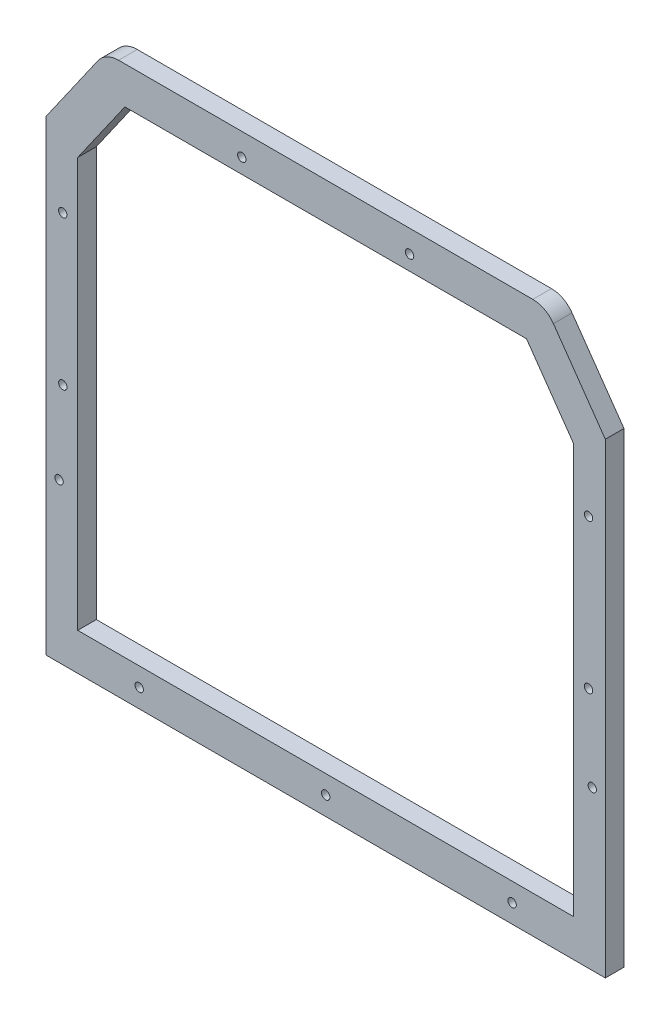
from build123d import *

# Parameters (mm, degrees)
SALIENTE_EXTRUIR1_DEPTH = 10
CROQUIS2_R              = 2.25
CORTAR_EXTRUIR1_DEPTH   = 11
CROQUIS3_R              = 2.25
CORTAR_EXTRUIR2_DEPTH   = 10
CROQUIS4_OUTSIDE_W      = 393.144
CROQUIS4_OUTSIDE_H      = 382.951
CROQUIS4_OUTSIDE_W_2    = 300
CROQUIS4_OUTSIDE_H_2    = 346.918637929
CORTAR_EXTRUIR3_DEPTH   = 10


with BuildPart() as part:
    # Croquis1 → Saliente-Extruir1 (new body)
    with BuildSketch(Plane.XY):
        with BuildLine():
            Line((303.558552598, 129.486748241), (275.155897415, 170.049943626))
            ThreePointArc((275.155897415, 170.049943626), (270.330951096, 174.281307983), (264.097344818, 175.806661735))
            Line((264.097344818, 175.806661735), (41.902655182, 175.806661735))
            ThreePointArc((41.902655182, 175.806661735), (35.669048904, 174.281307983), (30.844102585, 170.049943626))
            Line((30.844102585, 170.049943626), (2.441447402, 129.486748241))
            ThreePointArc((2.441447402, 129.486748241), (0.624821165, 125.802994643), (0, 121.74346635))
            Line((0, 121.74346635), (0, 0))
            Line((0, 0), (0, -120))
            Line((0, -120), (306, -120))
            Line((306, -120), (306, 0))
            Line((306, 0), (306, 121.74346635))
            ThreePointArc((306, 121.74346635), (305.375178835, 125.802994643), (303.558552598, 129.486748241))
        make_face()
        Polygon((20, 0), (20, 119.694024222), (45.286341011, 155.806661735), (260.713658989, 155.806661735), (286, 119.694024222), (286, 0), (286, -100), (20, -100), align=None, mode=Mode.SUBTRACT)
    extrude(amount=SALIENTE_EXTRUIR1_DEPTH)

    # Croquis2 → Cortar-Extruir1 (cut, through all)
    with BuildSketch(Plane.XY.offset(10)):
        with Locations((108, 163.806661735)):
            Circle(CROQUIS2_R)
        with Locations((198, 163.806661735)):
            Circle(CROQUIS2_R)
        with Locations((12, 10)):
            Circle(CROQUIS2_R)
        with Locations((294, 10)):
            Circle(CROQUIS2_R)
        with Locations((294, 90)):
            Circle(CROQUIS2_R)
        with Locations((12, 90)):
            Circle(CROQUIS2_R)
    extrude(amount=-CORTAR_EXTRUIR1_DEPTH, mode=Mode.SUBTRACT)

    # Croquis3 → Cortar-Extruir2 (cut)
    with BuildSketch(Plane.XY.offset(10)):
        with Locations((10, -35)):
            Circle(CROQUIS3_R)
        with Locations((296, -35)):
            Circle(CROQUIS3_R)
        with Locations((53, -110)):
            Circle(CROQUIS3_R)
        with Locations((153, -110)):
            Circle(CROQUIS3_R)
        with Locations((253, -110)):
            Circle(CROQUIS3_R)
    extrude(amount=-CORTAR_EXTRUIR2_DEPTH, mode=Mode.SUBTRACT)

    # Croquis4 outside → Cortar-Extruir3 (cut)
    with BuildSketch(Plane.XY.offset(10)):
        with Locations((153, 27.9035)):
            Rectangle(CROQUIS4_OUTSIDE_W, CROQUIS4_OUTSIDE_H)
        with Locations((153, 32.896001841)):
            Rectangle(CROQUIS4_OUTSIDE_W_2, CROQUIS4_OUTSIDE_H_2, mode=Mode.SUBTRACT)
    extrude(amount=-CORTAR_EXTRUIR3_DEPTH, mode=Mode.SUBTRACT)


solid = part.part
